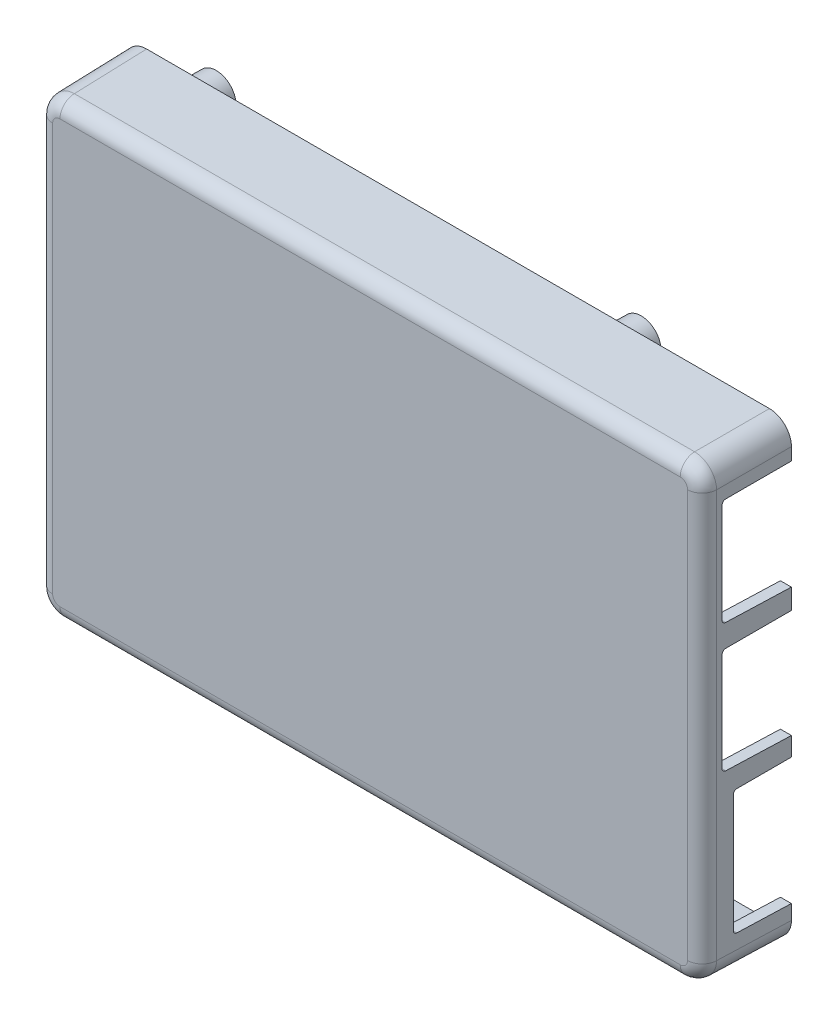
from build123d import *

# Parameters (mm, degrees)
SKETCH1_W                   = 91
SKETCH1_H                   = 62
SKETCH1_W_2                 = 88
SKETCH1_H_2                 = 59
WALLS_DEPTH                 = 12
SKETCH2_W                   = 91
SKETCH2_H                   = 62
TOP_FACE_DEPTH              = 1.5
SKETCH3_R                   = 3
STANDOFFS_DEPTH             = 16.5
STANDOFFS_DRAFT             = 1
STANDOFFS_PROFILE_2_DEPTH   = 16.5
STANDOFFS_PROFILE_2_DRAFT   = 1
STANDOFFS_PROFILE_3_DEPTH   = 16.5
STANDOFFS_PROFILE_3_DRAFT   = 1
STANDOFFS_PROFILE_4_DEPTH   = 16.5
STANDOFFS_PROFILE_4_DRAFT   = 1
M2X0_4_TAPPED_HOLE1_D       = 1.6
M2X0_4_TAPPED_HOLE1_DEPTH   = 5
M2X0_4_TAPPED_HOLE1_TIP     = 0.480688495
USB_START                   = 30
SKETCH7_W                   = 14.2
SKETCH7_H                   = 17.304
SKETCH7_W_2                 = 16.490000002
SKETCH7_H_2                 = 14.78
SKETCH7_H_3                 = 14.9
USB_AND_ETHERNET_CUTS_DEPTH = 27.349356695
DRAFT1_ANGLE                = -1
DRAFT2_ANGLE                = 1
FILLET1_R                   = 3
FILLET2_R                   = 1.5
FILLET3_R                   = 2
FILLET4_R                   = 0.5
DRAFT3_ANGLE                = 1
FILLET5_R                   = 0.5


with BuildPart() as part:
    # Sketch1 → Walls (new body)
    with BuildSketch(Plane.XY):
        Rectangle(SKETCH1_W, SKETCH1_H)
        Rectangle(SKETCH1_W_2, SKETCH1_H_2, mode=Mode.SUBTRACT)
    extrude(amount=WALLS_DEPTH)

    # Sketch2 → Top Face (add)
    with BuildSketch(Plane.XY.offset(12)):
        Rectangle(SKETCH2_W, SKETCH2_H)
    extrude(amount=-TOP_FACE_DEPTH)


with BuildPart() as standoffs_tool:
    # Sketch3 → Standoffs (with draft: the straight prism first)
    with BuildSketch(Plane(origin=(0, 0, 10.5), x_dir=(-1, 0, 0), z_dir=(0, 0, -1))):
        with Locations((39, -24.5)):
            Circle(SKETCH3_R)
    extrude(amount=STANDOFFS_DEPTH)
    # Standoffs: the draft: its side faces are tilted about the plane it starts from
    standoffs_sides = [standoffs_tool.faces().sort_by_distance(p)[0] for p in [
        (-36, -24.5, 2.25),
    ]]
    draft(standoffs_sides, Plane(origin=(0, 0, 10.5), x_dir=(-1, 0, 0), z_dir=(0, 0, -1)), STANDOFFS_DRAFT)


with BuildPart() as part_1:
    add(part.part)

    # Standoffs: add standoffs_tool
    add(standoffs_tool.part)


with BuildPart() as standoffs_profile_2_tool:
    # Sketch3 → Standoffs profile 2 (with draft: the straight prism first)
    with BuildSketch(Plane(origin=(0, 0, 10.5), x_dir=(-1, 0, 0), z_dir=(0, 0, -1))):
        with Locations((-19, -24.5)):
            Circle(SKETCH3_R)
    extrude(amount=STANDOFFS_PROFILE_2_DEPTH)
    # Standoffs profile 2: the draft: its side faces are tilted about the plane it starts from
    standoffs_profile_2_sides = [standoffs_profile_2_tool.faces().sort_by_distance(p)[0] for p in [
        (22, -24.5, 2.25),
    ]]
    draft(standoffs_profile_2_sides, Plane(origin=(0, 0, 10.5), x_dir=(-1, 0, 0), z_dir=(0, 0, -1)), STANDOFFS_PROFILE_2_DRAFT)


with BuildPart() as part_2:
    add(part_1.part)

    # Standoffs profile 2: add standoffs_profile_2_tool
    add(standoffs_profile_2_tool.part)


with BuildPart() as standoffs_profile_3_tool:
    # Sketch3 → Standoffs profile 3 (with draft: the straight prism first)
    with BuildSketch(Plane(origin=(0, 0, 10.5), x_dir=(-1, 0, 0), z_dir=(0, 0, -1))):
        with Locations((39, 24.5)):
            Circle(SKETCH3_R)
    extrude(amount=STANDOFFS_PROFILE_3_DEPTH)
    # Standoffs profile 3: the draft: its side faces are tilted about the plane it starts from
    standoffs_profile_3_sides = [standoffs_profile_3_tool.faces().sort_by_distance(p)[0] for p in [
        (-36, 24.5, 2.25),
    ]]
    draft(standoffs_profile_3_sides, Plane(origin=(0, 0, 10.5), x_dir=(-1, 0, 0), z_dir=(0, 0, -1)), STANDOFFS_PROFILE_3_DRAFT)


with BuildPart() as part_3:
    add(part_2.part)

    # Standoffs profile 3: add standoffs_profile_3_tool
    add(standoffs_profile_3_tool.part)


with BuildPart() as standoffs_profile_4_tool:
    # Sketch3 → Standoffs profile 4 (with draft: the straight prism first)
    with BuildSketch(Plane(origin=(0, 0, 10.5), x_dir=(-1, 0, 0), z_dir=(0, 0, -1))):
        with Locations((-19, 24.5)):
            Circle(SKETCH3_R)
    extrude(amount=STANDOFFS_PROFILE_4_DEPTH)
    # Standoffs profile 4: the draft: its side faces are tilted about the plane it starts from
    standoffs_profile_4_sides = [standoffs_profile_4_tool.faces().sort_by_distance(p)[0] for p in [
        (22, 24.5, 2.25),
    ]]
    draft(standoffs_profile_4_sides, Plane(origin=(0, 0, 10.5), x_dir=(-1, 0, 0), z_dir=(0, 0, -1)), STANDOFFS_PROFILE_4_DRAFT)


with BuildPart() as part_4:
    add(part_3.part)

    # Standoffs profile 4: add standoffs_profile_4_tool
    add(standoffs_profile_4_tool.part)

    # M2x0.4 Tapped Hole1
    with Locations(Plane(origin=(0, 0, -6), x_dir=(-1, 0, 0), z_dir=(0, 0, -1))):
        with Locations((-19, -24.5), (-19, 24.5), (39, 24.5), (39, -24.5)):
            Hole(M2X0_4_TAPPED_HOLE1_D / 2, depth=M2X0_4_TAPPED_HOLE1_DEPTH)
            with Locations((0, 0, -(M2X0_4_TAPPED_HOLE1_DEPTH + M2X0_4_TAPPED_HOLE1_TIP / 2))):  # 118° drill point
                Cone(0, M2X0_4_TAPPED_HOLE1_D / 2, M2X0_4_TAPPED_HOLE1_TIP, mode=Mode.SUBTRACT)

    # Sketch7 → USB and Ethernet Cuts (cut, through all)
    with BuildSketch(Plane(origin=(0, 0, 0), x_dir=(0, 0, -1), z_dir=(1, 0, 0)).offset(USB_START)):
        with Locations((-0.7, -17.348)):
            Rectangle(SKETCH7_W, SKETCH7_H)
        with Locations((-1.054999999, 1.25)):
            Rectangle(SKETCH7_W_2, SKETCH7_H_2)
        with Locations((-1.054999999, 18.85)):
            Rectangle(SKETCH7_W_2, SKETCH7_H_3)
    extrude(amount=USB_AND_ETHERNET_CUTS_DEPTH, mode=Mode.SUBTRACT)

    # Draft1
    draft1_faces = [part_4.faces().sort_by_distance(p)[0] for p in [
        (0, 31, 6),
        (45.5, -28.5, 0.631506136),
        (-45.5, 0, 6),
        (0, -31, 6),
    ]]
    draft(draft1_faces, Plane(origin=(0, 0, 0), x_dir=(-1, 0, 0), z_dir=(0, 0, -1)), DRAFT1_ANGLE)

    # Draft2
    draft2_faces = [part_4.faces().sort_by_distance(p)[0] for p in [
        (0, -29.5, 5.25),
        (-44, 0, 5.25),
        (0, 29.5, 5.25),
        (44, -27.75, 0.59927039),
    ]]
    draft(draft2_faces, Plane(origin=(0, 0, 0), x_dir=(-1, 0, 0), z_dir=(0, 0, -1)), DRAFT2_ANGLE)

    # Fillet1
    fillet1_edges = [part_4.edges().sort_by_distance(p)[0] for p in [
        (45.39526961, 30.89526961, 6),
        (45.39526961, -30.89526961, 6),
        (-45.39526961, -30.89526961, 6),
        (-45.39526961, 30.89526961, 6),
    ]]
    fillet(fillet1_edges, radius=FILLET1_R)

    # Fillet2
    fillet2_edges = [part_4.edges().sort_by_distance(p)[0] for p in [
        (43.908360909, -29.408360909, 5.25),
        (43.908360909, 29.408360909, 5.25),
        (-43.908360909, -29.408360909, 5.25),
        (-43.908360909, 29.408360909, 5.25),
    ]]
    fillet(fillet2_edges, radius=FILLET2_R)

    # Fillet3
    fillet3_edges = [part_4.edges().sort_by_distance(p)[0] for p in [
        (-45.290539221, 0, 12),
        (0, 30.790539221, 12),
        (0, -30.790539221, 12),
        (45.290539221, 0, 12),
        (44.412048804, -29.912048804, 12),
        (44.412048804, 29.912048804, 12),
        (-44.412048804, -29.912048804, 12),
        (-44.412048804, 29.912048804, 12),
    ]]
    fillet(fillet3_edges, radius=FILLET3_R)

    # Fillet4
    fillet4_edges = [part_4.edges().sort_by_distance(p)[0] for p in [
        (0, 29.316721818, 10.5),
        (-43.816721818, 0, 10.5),
        (43.816721818, 0, 10.5),
        (0, -29.316721818, 10.5),
        (43.37747661, -28.87747661, 10.5),
        (43.37747661, 28.87747661, 10.5),
        (-43.37747661, -28.87747661, 10.5),
        (-43.37747661, 28.87747661, 10.5),
        (-36, -24.5, 10.5),
        (22, -24.5, 10.5),
        (-36, 24.5, 10.5),
        (22, 24.5, 10.5),
    ]]
    fillet(fillet4_edges, radius=FILLET4_R)

    # Draft3
    draft3_faces = [part_4.faces().sort_by_distance(p)[0] for p in [
        (44.681925247, -8.696, 3.9),
        (44.668833948, 8.64, 4.65),
        (44.668833948, 26.3, 4.65),
        (44.668833948, 11.4, 4.65),
        (44.668833948, -6.14, 4.65),
        (44.681925247, -26, 3.9),
    ]]
    draft(draft3_faces, Plane(origin=(0, 0, 0), x_dir=(-1, 0, 0), z_dir=(0, 0, -1)), DRAFT3_ANGLE)

    # Fillet5
    fillet5_edges = [part_4.edges().sort_by_distance(p)[0] for p in [
        (44.587667896, 8.477667896, 9.3),
        (44.587667896, -5.977667896, 9.3),
        (44.587667896, 26.137667896, 9.3),
        (44.587667896, 11.562332104, 9.3),
        (44.613850494, -8.832149506, 7.8),
        (44.613850494, -25.863850494, 7.8),
    ]]
    fillet(fillet5_edges, radius=FILLET5_R)


solid = part_4.part
